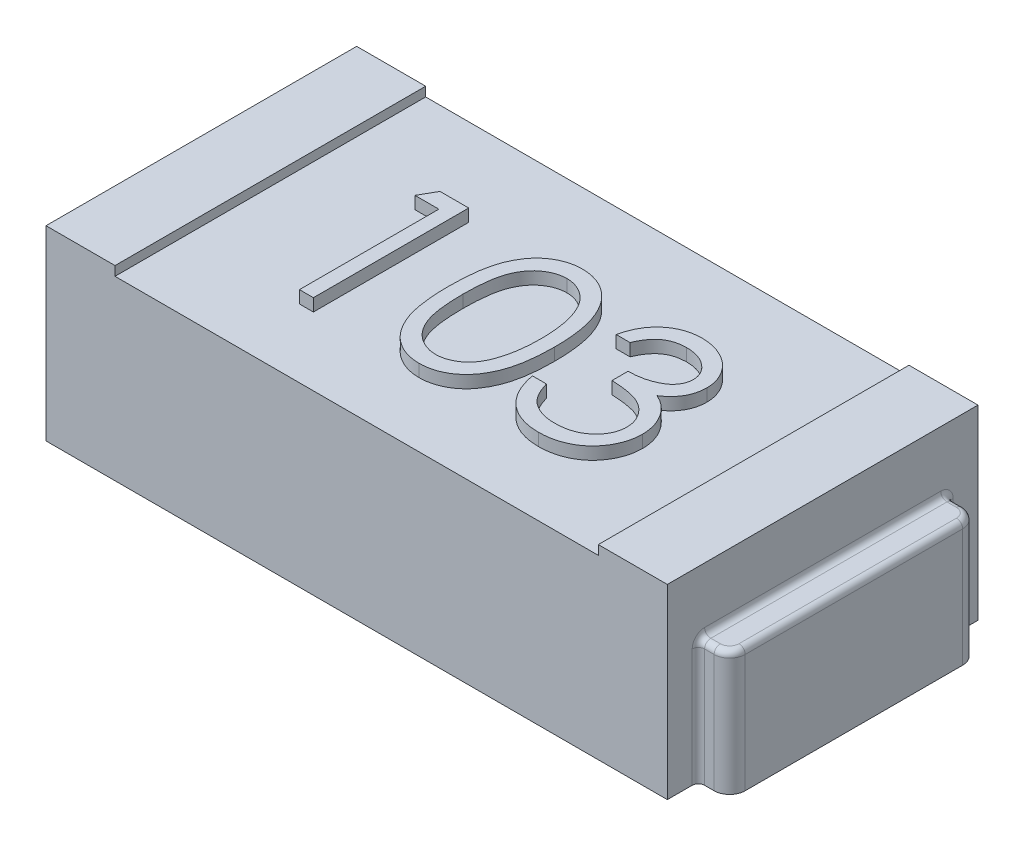
from build123d import *

# Parameters (mm, degrees)
ESQUISSE1_W             = 2
ESQUISSE1_H             = 1
BOSS_EXTRU_1_DEPTH      = 0.6
ESQUISSE2_W             = 1.555645222
ESQUISSE2_H             = 1
ENL_V_MAT_EXTRU_1_DEPTH = 0.03
BOSS_EXTRU_2_DEPTH      = 0.4
CONG_1_R                = 0.02
CONG_1_OF_SYM_TRIE2_R   = 0.02
BOSS_EXTRU_3_DEPTH      = 0.04


with BuildPart() as part:
    # Esquisse1 → Boss.-Extru.1 (new body)
    with BuildSketch(Plane(origin=(0, 0, 0), x_dir=(1, 0, 0), z_dir=(0, 1, 0))):
        Rectangle(ESQUISSE1_W, ESQUISSE1_H)
    extrude(amount=BOSS_EXTRU_1_DEPTH)

    # Esquisse2 → Enlèv. mat.-Extru.1 (cut)
    with BuildSketch(Plane(origin=(0, 0.6, 0), x_dir=(1, 0, 0), z_dir=(0, 1, 0))):
        Rectangle(ESQUISSE2_W, ESQUISSE2_H)
    extrude(amount=-ENL_V_MAT_EXTRU_1_DEPTH, mode=Mode.SUBTRACT)

    # Esquisse3 → Boss.-Extru.2 (add)
    with BuildSketch(Plane(origin=(0, 0, 0), x_dir=(1, 0, 0), z_dir=(0, 1, 0))):
        with BuildLine():
            Line((1, 0.4), (1.050552667, 0.4))
            ThreePointArc((1.050552667, 0.4), (1.085908006, 0.385355339), (1.100552667, 0.35))
            Line((1.100552667, 0.35), (1.100552667, -0.35))
            ThreePointArc((1.100552667, -0.35), (1.085908006, -0.385355339), (1.050552667, -0.4))
            Line((1.050552667, -0.4), (1, -0.4))
            Line((1, -0.4), (1, 0.4))
        make_face()
    boss_extru_2 = extrude(amount=BOSS_EXTRU_2_DEPTH)

    # Congé1
    cong_1_edges = [part.edges().sort_by_distance(p)[0] for p in [
        (1, 0.2, -0.4),
        (1, 0.2, 0.4),
        (1, 0.4, 0),
        (1.025276334, 0.4, 0.4),
        (1.085908006, 0.4, 0.385355339),
        (1.100552667, 0.4, 0),
        (1.085908006, 0.4, -0.385355339),
        (1.025276334, 0.4, -0.4),
    ]]
    fillet(cong_1_edges, radius=CONG_1_R)

    # Symétrie2: Boss.-Extru.2 across plane
    add(boss_extru_2.mirror(Plane(origin=(0, 0, 0), x_dir=(0, 0, 1), z_dir=(1, 0, 0))))

    # Congé1 of Symétrie2
    cong_1_of_sym_trie2_edges = [part.edges().sort_by_distance(p)[0] for p in [
        (-1, 0.2, -0.4),
        (-1, 0.2, 0.4),
        (-1, 0.4, 0),
        (-1.025276334, 0.4, 0.4),
        (-1.085908006, 0.4, 0.385355339),
        (-1.100552667, 0.4, 0),
        (-1.085908006, 0.4, -0.385355339),
        (-1.025276334, 0.4, -0.4),
    ]]
    fillet(cong_1_of_sym_trie2_edges, radius=CONG_1_OF_SYM_TRIE2_R)

    # Esquisse4 → Boss.-Extru.3 (add)
    with BuildSketch(Plane(origin=(0, 0.57, 0), x_dir=(1, 0, 0), z_dir=(0, 1, 0))):
        with BuildLine():
            Line((0.275641026, 0.104315862), (0.230769231, 0.104315862))
            add(Edge.make_bspline(
                [(0.230769231, 0.104315862), (0.231984881, 0.109349074), (0.234361377, 0.119188592), (0.239318174, 0.133246772), (0.244718067, 0.146550132), (0.251202225, 0.158849571), (0.258274904, 0.170392272), (0.26637815, 0.180916432), (0.27513811, 0.190689713), (0.284827389, 0.199363033), (0.294988626, 0.207216994), (0.305765001, 0.213913431), (0.3169397, 0.219674024), (0.328590147, 0.224419771), (0.340751029, 0.227994846), (0.353312404, 0.230588676), (0.366307189, 0.23227312), (0.375128274, 0.232437515), (0.379607372, 0.23252099)],
                knots=[0, 0, 0, 0, 1.5524e-05, 3.0347e-05, 4.467e-05, 5.8558e-05, 7.201e-05, 8.5231e-05, 9.8349e-05, 0.000111325, 0.000124187, 0.000136831, 0.000149329, 0.000161865, 0.00017451, 0.000187298, 0.000200318, 0.000213748, 0.000213748, 0.000213748, 0.000213748], degree=3))
            add(Edge.make_bspline(
                [(0.379607372, 0.23252099), (0.386133478, 0.232323957), (0.399043337, 0.231934189), (0.418009486, 0.228374984), (0.436299032, 0.222742822), (0.453711781, 0.214960861), (0.469885843, 0.205362674), (0.484276727, 0.19393914), (0.496689371, 0.180910668), (0.507102854, 0.166520302), (0.515256425, 0.151140943), (0.521268764, 0.13531235), (0.524929004, 0.119072068), (0.52540337, 0.108106742), (0.525641026, 0.102613138)],
                knots=[0, 0, 0, 0, 1.9562e-05, 3.8698e-05, 5.7675e-05, 7.6865e-05, 9.5777e-05, 0.000113954, 0.000131807, 0.000149598, 0.000167073, 0.000183872, 0.000200276, 0.000216747, 0.000216747, 0.000216747, 0.000216747], degree=3))
            add(Edge.make_bspline(
                [(0.525641026, 0.102613138), (0.525474798, 0.097326453), (0.525149517, 0.086981231), (0.522387559, 0.07187816), (0.517739522, 0.057643645), (0.511300984, 0.044217765), (0.502966477, 0.031685645), (0.492870378, 0.020019089), (0.480941426, 0.009166352), (0.471901578, 0.002949285), (0.467247596, -0.000251446)],
                knots=[0, 0, 0, 0, 1.5851e-05, 3.1018e-05, 4.5873e-05, 6.0656e-05, 7.5546e-05, 9.0886e-05, 0.000106841, 0.00012377, 0.00012377, 0.00012377, 0.00012377], degree=3))
            add(Edge.make_bspline(
                [(0.467247596, -0.000251446), (0.472566418, -0.002819756), (0.483104543, -0.007908321), (0.497468904, -0.017887715), (0.510508601, -0.029410051), (0.517780561, -0.038401858), (0.521434295, -0.042919715)],
                knots=[0, 0, 0, 0, 1.7695e-05, 3.5058e-05, 5.2293e-05, 6.9697e-05, 6.9697e-05, 6.9697e-05, 6.9697e-05], degree=3))
            add(Edge.make_bspline(
                [(0.521434295, -0.042919715), (0.523840201, -0.046213679), (0.528612615, -0.052747668), (0.534503405, -0.063252871), (0.539847564, -0.073874513), (0.544011881, -0.084897285), (0.54723672, -0.09619343), (0.549541867, -0.107782343), (0.550973887, -0.119673489), (0.551178966, -0.127718129), (0.551282051, -0.131761862)],
                knots=[0, 0, 0, 0, 1.2226e-05, 2.4252e-05, 3.6078e-05, 4.7871e-05, 5.9538e-05, 7.1285e-05, 8.3286e-05, 9.5416e-05, 9.5416e-05, 9.5416e-05, 9.5416e-05], degree=3))
            add(Edge.make_bspline(
                [(0.551282051, -0.131761862), (0.551025692, -0.138763251), (0.55051418, -0.15273308), (0.54594217, -0.173372326), (0.538854564, -0.193547398), (0.528789287, -0.212843803), (0.516522501, -0.230898143), (0.501928597, -0.247051902), (0.485173396, -0.260937417), (0.466486875, -0.272538878), (0.446241571, -0.281812867), (0.424587915, -0.288249644), (0.401837907, -0.29244193), (0.386236864, -0.292891483), (0.378305288, -0.293120035)],
                knots=[0, 0, 0, 0, 2.098e-05, 4.1862e-05, 6.3119e-05, 8.498e-05, 0.000106955, 0.000128441, 0.000150062, 0.000172018, 0.00019425, 0.000216652, 0.00023964, 0.000263413, 0.000263413, 0.000263413, 0.000263413], degree=3))
            add(Edge.make_bspline(
                [(0.378305288, -0.293120035), (0.372959674, -0.292996005), (0.362441288, -0.292751954), (0.346977931, -0.291083583), (0.332217688, -0.288036439), (0.318140603, -0.283935967), (0.304734169, -0.278737147), (0.292039297, -0.272263047), (0.279977883, -0.264647118), (0.268663747, -0.255799463), (0.258098238, -0.245902128), (0.248562134, -0.234779413), (0.23989645, -0.222636926), (0.232333215, -0.209333633), (0.225527937, -0.195041453), (0.219930657, -0.179577382), (0.215004147, -0.163079664), (0.212713652, -0.151582844), (0.211538462, -0.145684138)],
                knots=[0, 0, 0, 0, 1.6037e-05, 3.1555e-05, 4.6582e-05, 6.1194e-05, 7.5497e-05, 8.9652e-05, 0.000103879, 0.000118224, 0.000132679, 0.000147236, 0.000162105, 0.000177361, 0.000193087, 0.000209535, 0.00022665, 0.000244684, 0.000244684, 0.000244684, 0.000244684], degree=3))
            Line((0.211538462, -0.145684138), (0.256410256, -0.145684138))
            add(Edge.make_bspline(
                [(0.256410256, -0.145684138), (0.257579298, -0.149533997), (0.259853186, -0.157022307), (0.2637238, -0.167799494), (0.268133553, -0.177679216), (0.272864204, -0.186733947), (0.277832553, -0.195052862), (0.283391828, -0.202415986), (0.289130278, -0.209146729), (0.2934559, -0.212938817), (0.295572917, -0.214794715)],
                knots=[0, 0, 0, 0, 1.207e-05, 2.3476e-05, 3.4328e-05, 4.4497e-05, 5.4117e-05, 6.3352e-05, 7.2152e-05, 8.0588e-05, 8.0588e-05, 8.0588e-05, 8.0588e-05], degree=3))
            add(Edge.make_bspline(
                [(0.295572917, -0.214794715), (0.298372428, -0.216953048), (0.303962808, -0.221263053), (0.313072555, -0.226763286), (0.322653253, -0.231529146), (0.332912492, -0.235169674), (0.343628888, -0.238252197), (0.354975655, -0.240269414), (0.366852686, -0.241653439), (0.374962366, -0.241775572), (0.379106571, -0.241837984)],
                knots=[0, 0, 0, 0, 1.0597e-05, 2.1162e-05, 3.1867e-05, 4.2641e-05, 5.3771e-05, 6.5283e-05, 7.7174e-05, 8.96e-05, 8.96e-05, 8.96e-05, 8.96e-05], degree=3))
            add(Edge.make_bspline(
                [(0.379106571, -0.241837984), (0.383785642, -0.241749998), (0.392935163, -0.241577948), (0.406285857, -0.239995704), (0.418986921, -0.237691359), (0.430897339, -0.234132362), (0.442173126, -0.229735097), (0.452656219, -0.224213896), (0.462484234, -0.217736079), (0.471531292, -0.210373342), (0.479666365, -0.202313128), (0.486829152, -0.19388269), (0.49291839, -0.185117571), (0.497830329, -0.175969268), (0.501708979, -0.166475664), (0.504349437, -0.156610117), (0.506185367, -0.146453365), (0.506334883, -0.139549226), (0.506410256, -0.136068753)],
                knots=[0, 0, 0, 0, 1.4031e-05, 2.7437e-05, 4.0284e-05, 5.2708e-05, 6.4668e-05, 7.654e-05, 8.818e-05, 9.9927e-05, 0.000111472, 0.000122488, 0.000133073, 0.000143425, 0.000153581, 0.000163762, 0.000174021, 0.000184449, 0.000184449, 0.000184449, 0.000184449], degree=3))
            add(Edge.make_bspline(
                [(0.506410256, -0.136068753), (0.506191642, -0.131409991), (0.505755501, -0.122115647), (0.502425704, -0.108441707), (0.496948723, -0.095266934), (0.489281221, -0.082816107), (0.479947546, -0.071276693), (0.469038273, -0.060980767), (0.456462812, -0.052485039), (0.444888545, -0.046615231), (0.43463638, -0.042609935), (0.425862754, -0.039942083), (0.416040382, -0.037682989), (0.405288046, -0.035581236), (0.39352473, -0.033792472), (0.380763238, -0.032300784), (0.367000987, -0.031107207), (0.357473677, -0.030574193), (0.352564103, -0.030299523)],
                knots=[0, 0, 0, 0, 1.3966e-05, 2.7862e-05, 4.1962e-05, 5.6614e-05, 7.1569e-05, 8.6379e-05, 0.000101437, 0.000116935, 0.000125212, 0.000134432, 0.000144417, 0.000155437, 0.000167294, 0.000180102, 0.000193977, 0.000208728, 0.000208728, 0.000208728, 0.000208728], degree=3))
            Line((0.352564103, -0.030299523), (0.352564103, 0.020982529))
            add(Edge.make_bspline(
                [(0.352564103, 0.020982529), (0.358749983, 0.021087501), (0.370866604, 0.021293115), (0.388565791, 0.023779974), (0.40549055, 0.027220063), (0.421265798, 0.032489376), (0.435644186, 0.038609419), (0.448118415, 0.045731163), (0.458513722, 0.053647556), (0.466779589, 0.062480786), (0.47299805, 0.071954364), (0.477544736, 0.081828172), (0.480230497, 0.092188752), (0.48058902, 0.099259419), (0.480769231, 0.102813458)],
                knots=[0, 0, 0, 0, 1.8543e-05, 3.6321e-05, 5.353e-05, 7.0285e-05, 8.612e-05, 0.000100345, 0.000113267, 0.000125173, 0.000136452, 0.00014712, 0.000157663, 0.000168319, 0.000168319, 0.000168319, 0.000168319], degree=3))
            add(Edge.make_bspline(
                [(0.480769231, 0.102813458), (0.480710029, 0.105424565), (0.48059225, 0.110619237), (0.479106925, 0.118208533), (0.476874919, 0.125565811), (0.473806386, 0.132659783), (0.469699215, 0.139441251), (0.464784074, 0.14596803), (0.458931489, 0.152202855), (0.452224996, 0.158014329), (0.44502331, 0.163552792), (0.437130485, 0.16825474), (0.428784503, 0.172275463), (0.419976123, 0.175591106), (0.410676762, 0.17808529), (0.400930111, 0.179876125), (0.390717585, 0.18099579), (0.383750194, 0.181156992), (0.380208333, 0.181238939)],
                knots=[0, 0, 0, 0, 7.823e-06, 1.5563e-05, 2.3104e-05, 3.0863e-05, 3.8679e-05, 4.6832e-05, 5.5336e-05, 6.4278e-05, 7.3432e-05, 8.2553e-05, 9.1782e-05, 0.000101195, 0.000110744, 0.000120626, 0.000130901, 0.000141526, 0.000141526, 0.000141526, 0.000141526], degree=3))
            add(Edge.make_bspline(
                [(0.380208333, 0.181238939), (0.374515238, 0.181040173), (0.363395298, 0.180651937), (0.347364596, 0.177251506), (0.332461834, 0.171826066), (0.321070596, 0.16534992), (0.3126588, 0.158957001), (0.306647808, 0.153373803), (0.300744878, 0.147169114), (0.295338353, 0.139960774), (0.289870642, 0.132236947), (0.284892848, 0.123604993), (0.280055749, 0.114290079), (0.277141099, 0.107704989), (0.275641026, 0.104315862)],
                knots=[0, 0, 0, 0, 1.7063e-05, 3.3328e-05, 4.8919e-05, 6.4486e-05, 7.2419e-05, 8.0571e-05, 8.9075e-05, 9.807e-05, 0.000107572, 0.00011745, 0.000127932, 0.000139048, 0.000139048, 0.000139048, 0.000139048], degree=3))
        make_face()
        with BuildLine():
            add(Edge.make_bspline(
                [(-0.173076923, -0.030499843), (-0.173030063, -0.022485931), (-0.172939038, -0.00691879), (-0.171926406, 0.01576473), (-0.170244214, 0.037044772), (-0.167938875, 0.056922352), (-0.16513345, 0.075402605), (-0.16138838, 0.092436141), (-0.157129408, 0.108101799), (-0.152193345, 0.122450663), (-0.14662366, 0.13567605), (-0.140561623, 0.148022507), (-0.133766653, 0.159471354), (-0.126627094, 0.170205324), (-0.11885394, 0.180048709), (-0.110668399, 0.189140518), (-0.101750988, 0.197270626), (-0.092404844, 0.20467724), (-0.082545349, 0.211170022), (-0.07245354, 0.216888984), (-0.062059953, 0.22177468), (-0.051336213, 0.225616171), (-0.040378704, 0.228789149), (-0.029149123, 0.230958998), (-0.017628929, 0.232324271), (-0.009853009, 0.232454795), (-0.005909455, 0.23252099)],
                knots=[0, 0, 0, 0, 2.404e-05, 4.6699e-05, 6.8101e-05, 8.8066e-05, 0.000106723, 0.000124149, 0.000140356, 0.000155402, 0.000169633, 0.000183384, 0.000196628, 0.000209546, 0.000222029, 0.000234224, 0.000246203, 0.000258186, 0.000269964, 0.00028158, 0.000292962, 0.000304369, 0.000315719, 0.000327152, 0.000338644, 0.00035047, 0.00035047, 0.00035047, 0.00035047], degree=3))
            add(Edge.make_bspline(
                [(-0.005909455, 0.23252099), (-0.001932958, 0.232451302), (0.005975043, 0.232312715), (0.017666525, 0.230980723), (0.029087908, 0.228770563), (0.0401905, 0.225638995), (0.051065498, 0.221753898), (0.061627842, 0.21688431), (0.071943139, 0.211215901), (0.081847466, 0.204555347), (0.091449554, 0.197129307), (0.100513548, 0.18873464), (0.109040275, 0.179456109), (0.117136747, 0.169392986), (0.124573261, 0.158352259), (0.13165518, 0.146525958), (0.137994042, 0.133707263), (0.144098996, 0.120110053), (0.149368565, 0.105358102), (0.154120886, 0.089534565), (0.157960739, 0.072452538), (0.161159206, 0.054201646), (0.163637048, 0.034714862), (0.165441712, 0.01403396), (0.16639501, -0.007854667), (0.166574538, -0.022820074), (0.166666667, -0.030499843)],
                knots=[0, 0, 0, 0, 1.1926e-05, 2.3717e-05, 3.5247e-05, 4.6791e-05, 5.8292e-05, 6.9855e-05, 8.1646e-05, 9.3563e-05, 0.000105625, 0.000118029, 0.000130574, 0.000143401, 0.000156736, 0.000170478, 0.000184722, 0.000199611, 0.000215168, 0.000231679, 0.000249148, 0.000267657, 0.000287249, 0.00030806, 0.000329918, 0.000352958, 0.000352958, 0.000352958, 0.000352958], degree=3))
            add(Edge.make_bspline(
                [(0.166666667, -0.030499843), (0.166573583, -0.038146116), (0.166392214, -0.053044566), (0.165452398, -0.074834705), (0.163601165, -0.095405854), (0.161285453, -0.114807349), (0.158078172, -0.132958437), (0.154134577, -0.14992193), (0.14975596, -0.165771083), (0.144350989, -0.180376056), (0.138435173, -0.193940588), (0.131998717, -0.206607324), (0.125103027, -0.218488222), (0.117590349, -0.229488186), (0.109582719, -0.239685137), (0.100908749, -0.248899083), (0.091812951, -0.257352037), (0.082182606, -0.264873698), (0.072123813, -0.271457241), (0.061843945, -0.277344934), (0.051160605, -0.282092462), (0.040315897, -0.286168896), (0.029154702, -0.289283247), (0.017690932, -0.291436655), (0.005982898, -0.292946919), (-0.001931611, -0.29306213), (-0.005909455, -0.293120035)],
                knots=[0, 0, 0, 0, 2.294e-05, 4.4698e-05, 6.541e-05, 8.4889e-05, 0.0001033, 0.000120672, 0.000137126, 0.000152589, 0.000167346, 0.000181501, 0.000195192, 0.000208527, 0.000221432, 0.000234046, 0.00024645, 0.000258652, 0.000270653, 0.000282492, 0.000294147, 0.000305682, 0.000317226, 0.000328855, 0.000340657, 0.000352583, 0.000352583, 0.000352583, 0.000352583], degree=3))
            add(Edge.make_bspline(
                [(-0.005909455, -0.293120035), (-0.0098529, -0.293053413), (-0.017628604, -0.292922047), (-0.029150379, -0.291562943), (-0.040333585, -0.289377871), (-0.051233407, -0.286318356), (-0.061905766, -0.282573379), (-0.072205236, -0.277694282), (-0.082246333, -0.272075129), (-0.09200227, -0.265675783), (-0.101289721, -0.258344114), (-0.110160951, -0.25023493), (-0.118393096, -0.241145871), (-0.12605511, -0.231220454), (-0.133337123, -0.22054999), (-0.140035605, -0.208988794), (-0.146231441, -0.196582707), (-0.151894797, -0.183251577), (-0.156916034, -0.168800873), (-0.161351421, -0.153065276), (-0.164853444, -0.135905899), (-0.167851009, -0.117460561), (-0.170268778, -0.09765), (-0.171919396, -0.07646346), (-0.172939583, -0.053914145), (-0.173030308, -0.038447034), (-0.173076923, -0.030499843)],
                knots=[0, 0, 0, 0, 1.1826e-05, 2.3318e-05, 3.475e-05, 4.5977e-05, 5.7256e-05, 6.8638e-05, 8.0117e-05, 9.1757e-05, 0.000103599, 0.000115578, 0.000127773, 0.000140335, 0.00015317, 0.0001665, 0.000180386, 0.000194748, 0.000209921, 0.000226252, 0.000243755, 0.000262428, 0.000282305, 0.000303608, 0.000326166, 0.000350006, 0.000350006, 0.000350006, 0.000350006], degree=3))
        make_face()
        with BuildLine():
            add(Edge.make_bspline(
                [(-0.128205128, -0.030299523), (-0.128188064, -0.036977908), (-0.128154947, -0.049939343), (-0.127289775, -0.068774095), (-0.126111171, -0.086341285), (-0.124590985, -0.102663218), (-0.122333421, -0.117684649), (-0.11980388, -0.131508889), (-0.116725582, -0.14406278), (-0.113083436, -0.155432467), (-0.108934994, -0.165810906), (-0.104405585, -0.175468222), (-0.099539767, -0.184518499), (-0.094094174, -0.192880443), (-0.088163451, -0.200581323), (-0.081881557, -0.207757442), (-0.075014045, -0.214157011), (-0.06551351, -0.221832276), (-0.052971157, -0.229763581), (-0.037168234, -0.236670165), (-0.020929884, -0.241010516), (-0.009908277, -0.241562481), (-0.004407051, -0.241837984)],
                knots=[0, 0, 0, 0, 2.0033e-05, 3.888e-05, 5.6549e-05, 7.2854e-05, 8.8039e-05, 0.000102104, 0.000115004, 0.000126787, 0.000137891, 0.00014851, 0.000158774, 0.000168692, 0.000178408, 0.000187915, 0.000197268, 0.000206529, 0.000224535, 0.00024158, 0.000258123, 0.000274609, 0.000274609, 0.000274609, 0.000274609], degree=3))
            add(Edge.make_bspline(
                [(-0.004407051, -0.241837984), (0.001129759, -0.24160973), (0.012191948, -0.241153692), (0.028353919, -0.236753873), (0.044043957, -0.230115367), (0.056339949, -0.222265723), (0.065694598, -0.214790248), (0.072397025, -0.208416726), (0.078548746, -0.201280174), (0.084383328, -0.193580275), (0.089734625, -0.18516992), (0.094600787, -0.176089552), (0.099041266, -0.166313955), (0.101571129, -0.159489707), (0.102864583, -0.156000644)],
                knots=[0, 0, 0, 0, 1.6578e-05, 3.3121e-05, 4.9903e-05, 6.7548e-05, 7.6668e-05, 8.5806e-05, 9.5248e-05, 0.000104903, 0.000114767, 0.000125119, 0.000135787, 0.000146948, 0.000146948, 0.000146948, 0.000146948], degree=3))
            add(Edge.make_bspline(
                [(0.102864583, -0.156000644), (0.104371979, -0.151539253), (0.107432638, -0.142480715), (0.111377177, -0.128428765), (0.114483663, -0.113685513), (0.117278429, -0.098339068), (0.119186009, -0.082276253), (0.12072141, -0.06554677), (0.121625794, -0.048138004), (0.121737902, -0.036310148), (0.121794872, -0.030299523)],
                knots=[0, 0, 0, 0, 1.4127e-05, 2.8683e-05, 4.3751e-05, 5.9313e-05, 7.5463e-05, 9.2257e-05, 0.000109708, 0.00012774, 0.00012774, 0.00012774, 0.00012774], degree=3))
            add(Edge.make_bspline(
                [(0.121794872, -0.030299523), (0.121716273, -0.024289869), (0.121562518, -0.012533703), (0.120974805, 0.00468318), (0.119457152, 0.021035717), (0.117771564, 0.036594356), (0.115286246, 0.051272971), (0.11260656, 0.065194443), (0.109006386, 0.078186304), (0.105160704, 0.090451958), (0.100759219, 0.101852052), (0.095914114, 0.112439736), (0.090739577, 0.122266125), (0.085119257, 0.131304259), (0.079119874, 0.139594623), (0.072583081, 0.146970993), (0.065768171, 0.153661989), (0.056222858, 0.161299499), (0.043726531, 0.169086884), (0.028177153, 0.176253421), (0.011995633, 0.180368891), (0.001056568, 0.180949132), (-0.004407051, 0.181238939)],
                knots=[0, 0, 0, 0, 1.8031e-05, 3.5273e-05, 5.1659e-05, 6.7289e-05, 8.2207e-05, 9.6311e-05, 0.000109795, 0.000122624, 0.000134863, 0.000146427, 0.000157539, 0.000168156, 0.000178333, 0.000188198, 0.000197689, 0.00020695, 0.000224818, 0.00024172, 0.000258142, 0.000274528, 0.000274528, 0.000274528, 0.000274528], degree=3))
            add(Edge.make_bspline(
                [(-0.004407051, 0.181238939), (-0.009937136, 0.180948732), (-0.02100738, 0.18036779), (-0.037357087, 0.176268754), (-0.053029138, 0.169124045), (-0.06549242, 0.161273706), (-0.075044389, 0.153796804), (-0.081770488, 0.147313025), (-0.088077084, 0.140220703), (-0.093886756, 0.132449001), (-0.099328082, 0.124096805), (-0.104325369, 0.11509841), (-0.108827845, 0.105408216), (-0.112982779, 0.095034439), (-0.116636034, 0.083665733), (-0.119649458, 0.071127305), (-0.122433322, 0.057347035), (-0.124404075, 0.042244248), (-0.12615604, 0.025918226), (-0.127281947, 0.008307181), (-0.128157841, -0.01055916), (-0.12818905, -0.023587611), (-0.128205128, -0.030299523)],
                knots=[0, 0, 0, 0, 1.6586e-05, 3.3202e-05, 5.0195e-05, 6.8064e-05, 7.7262e-05, 8.6542e-05, 9.6049e-05, 0.000105705, 0.000115623, 0.000125935, 0.000136554, 0.000147658, 0.000159441, 0.000172341, 0.000186327, 0.000201596, 0.000218011, 0.00023558, 0.000254527, 0.000274661, 0.000274661, 0.000274661, 0.000274661], degree=3))
        make_face(mode=Mode.SUBTRACT)
        Polygon((-0.451422276, 0.219700477), (-0.358974359, 0.219700477), (-0.358974359, -0.280299523), (-0.403846154, -0.280299523), (-0.403846154, 0.168418426), (-0.480769231, 0.168418426), align=None)
    extrude(amount=BOSS_EXTRU_3_DEPTH)


solid = part.part
